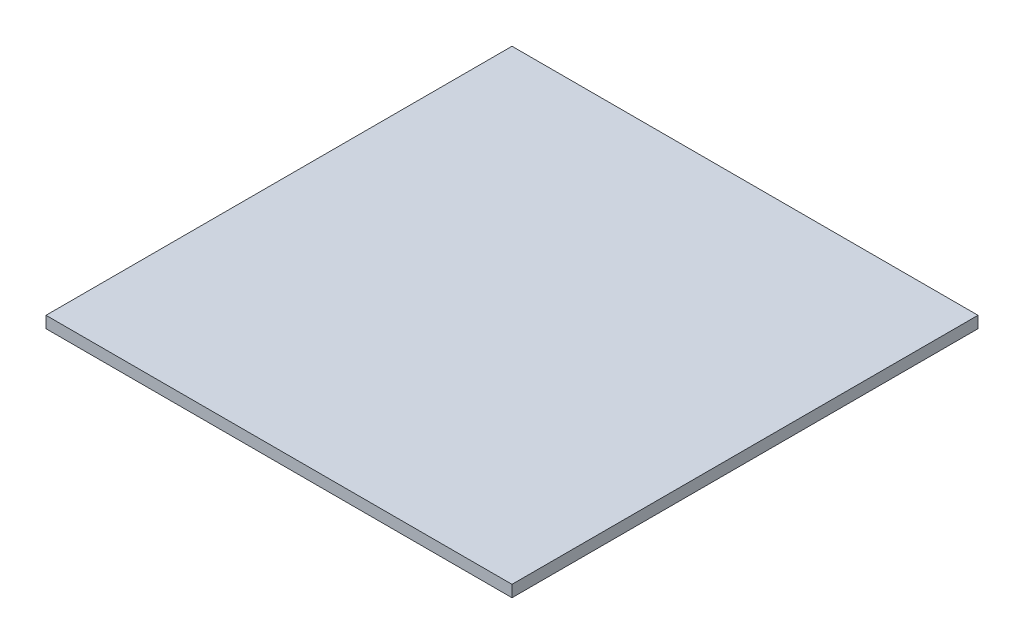
from build123d import *

# Parameters (mm, degrees)
SKETCH1_W           = 400
SKETCH1_H           = 400
BOSS_EXTRUDE1_DEPTH = 10


with BuildPart() as part:
    # Sketch1 → Boss-Extrude1 (new body)
    with BuildSketch(Plane(origin=(0, 0, 0), x_dir=(1, 0, 0), z_dir=(0, 1, 0))):
        Rectangle(SKETCH1_W, SKETCH1_H)
    extrude(amount=BOSS_EXTRUDE1_DEPTH)


solid = part.part
